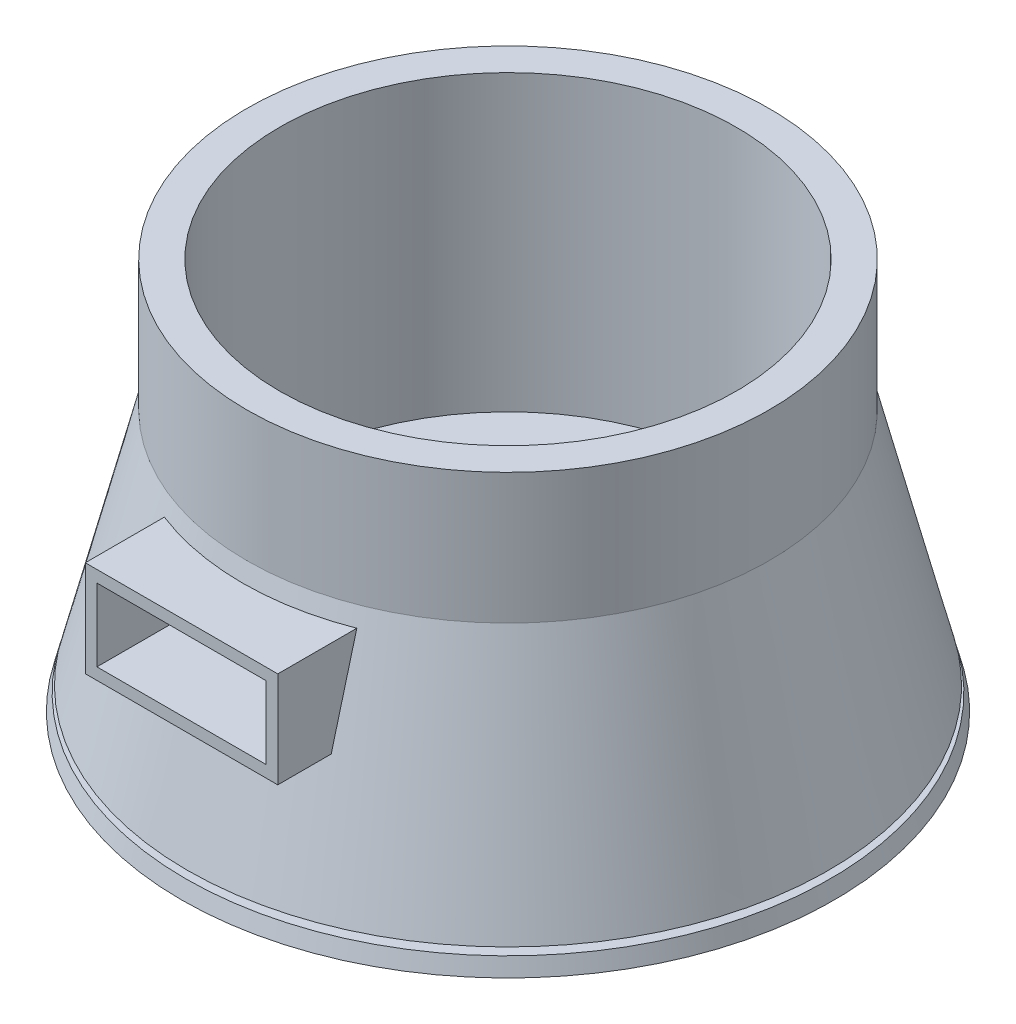
from build123d import *

# Parameters (mm, degrees)
SKETCH1_R           = 25
BOSS_EXTRUDE1_DEPTH = 30
SKETCH3_W           = 0.5
SKETCH3_H           = 0.75
SKETCH6_W           = 14.74
SKETCH6_H           = 7.36
SKETCH6_W_2         = 12.96
SKETCH6_H_2         = 5.56
BOSS_EXTRUDE2_DEPTH = 25
SKETCH4_R           = 17.5
CUT_EXTRUDE1_DEPTH  = 22.5
SKETCH6_5_W         = 12.96
SKETCH6_5_H         = 5.56
CUT_EXTRUDE7_DEPTH  = 46.5


with BuildPart() as part:
    # Sketch1 → Boss-Extrude1 (new body)
    with BuildSketch(Plane(origin=(0, 0, 0), x_dir=(1, 0, 0), z_dir=(0, 1, 0))):
        Circle(SKETCH1_R)
    extrude(amount=BOSS_EXTRUDE1_DEPTH)

    # Sketch3 → Cut-Revolve1 (revolve, cut)
    with BuildSketch(Plane.XY):
        Polygon((-24.5625, 1.75), (-20, 20), (-20, 30), (-25, 30), (-25, 0), (-24.6875, 1.25), (-23.75, 1.25), (-23.75, 1.75), align=None)
        Polygon((0, 0), (0, 20), (-5, 20), (-5, 2.5), (-15, 2.5), (-22.5, 0), align=None)
        with Locations((-23.75, 0.375)):
            Rectangle(SKETCH3_W, SKETCH3_H)
    revolve(axis=Axis((0, 31.461521879, 0), (0, -1, 0)), mode=Mode.SUBTRACT)

    # Sketch6 → Boss-Extrude2 (add)
    with BuildSketch(Plane.XY):
        with Locations((0, 15)):
            Rectangle(SKETCH6_W, SKETCH6_H)
        with Locations((0, 15)):
            Rectangle(SKETCH6_W_2, SKETCH6_H_2, mode=Mode.SUBTRACT)
    extrude(amount=BOSS_EXTRUDE2_DEPTH)

    # Sketch4 → Cut-Extrude1 (cut)
    with BuildSketch(Plane(origin=(0, 30, 0), x_dir=(1, 0, 0), z_dir=(0, 1, 0))):
        Circle(SKETCH4_R)
    extrude(amount=-CUT_EXTRUDE1_DEPTH, mode=Mode.SUBTRACT)

    # Sketch6_5 → Cut-Extrude7 (cut)
    with BuildSketch(Plane.XY):
        with Locations((0, 15)):
            Rectangle(SKETCH6_5_W, SKETCH6_5_H)
    extrude(amount=CUT_EXTRUDE7_DEPTH, mode=Mode.SUBTRACT)


solid = part.part
